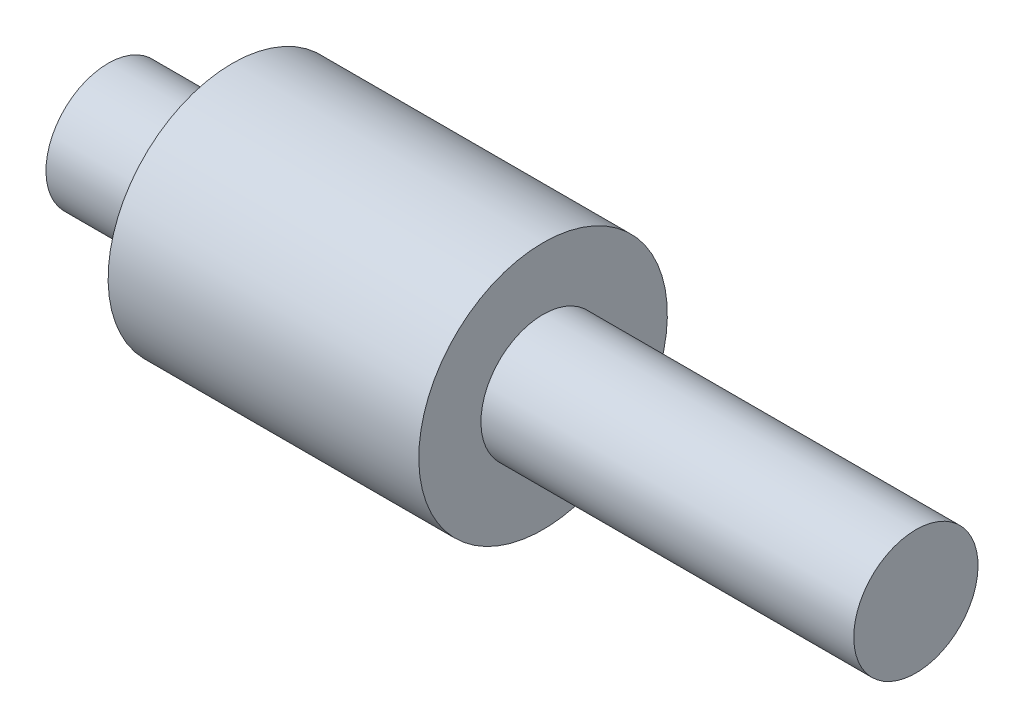
from build123d import *


with BuildPart() as part:
    # Sketch1 → Revolve1 (revolve)
    with BuildSketch(Plane.XY):
        Polygon((-35.768472635, 5.154644312), (-35.768472635, 8.329644312), (-29.418472635, 8.329644312), (-29.418472635, 11.504644312), (-13.543472635, 11.504644312), (-13.543472635, 8.329644312), (5.506527365, 8.329644312), (5.506527365, 5.154644312), align=None)
    revolve(axis=Axis((5.506527365, 5.154644312, 0), (-1, 0, 0)))


solid = part.part
